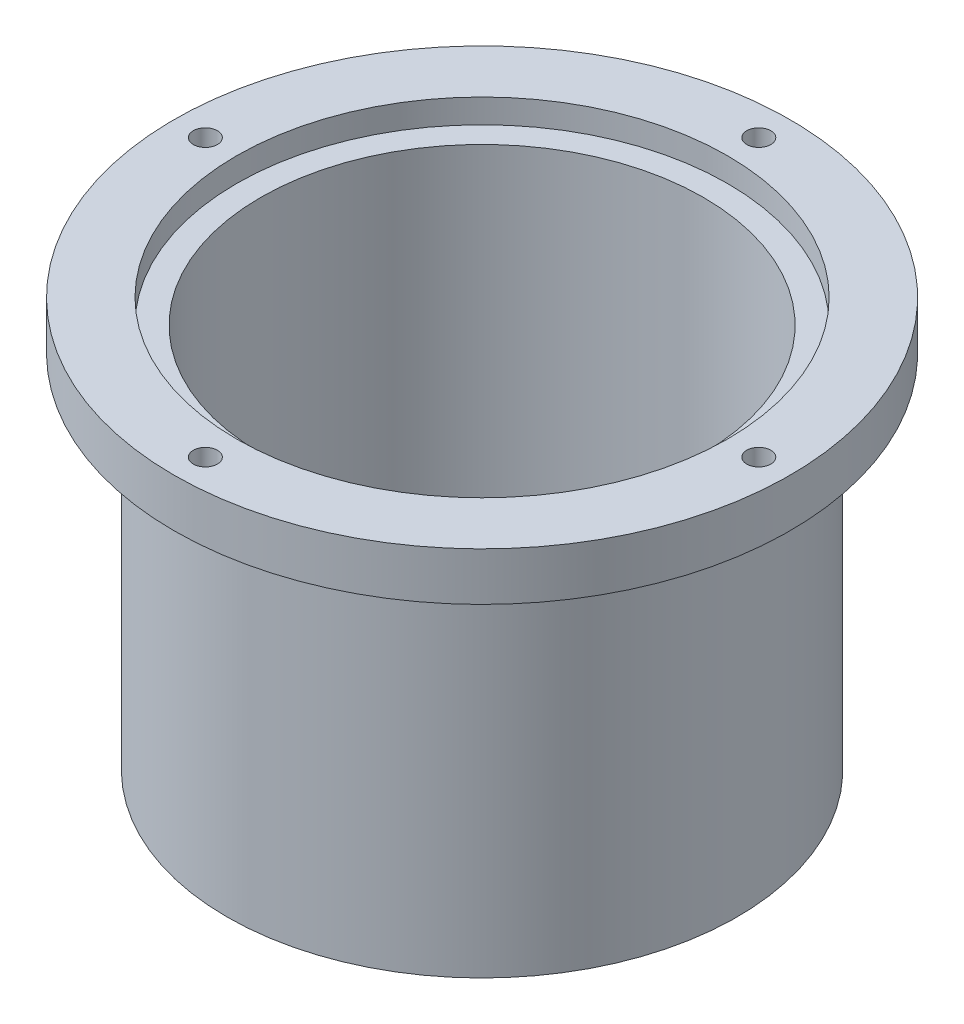
from build123d import *

# Parameters (mm, degrees)
SKETCH1_R           = 53
BOSS_EXTRUDE1_DEPTH = 75
SKETCH2_R           = 64
BOSS_EXTRUDE2_DEPTH = 10
SKETCH3_R           = 51
CUT_EXTRUDE1_DEPTH  = 5
SKETCH5_R           = 46
CUT_EXTRUDE2_DEPTH  = 66
SKETCH6_R           = 2.5
CUT_EXTRUDE3_DEPTH  = 66


with BuildPart() as part:
    # Sketch1 → Boss-Extrude1 (new body)
    with BuildSketch(Plane(origin=(0, 0, 0), x_dir=(1, 0, 0), z_dir=(0, 1, 0))):
        Circle(SKETCH1_R)
    extrude(amount=BOSS_EXTRUDE1_DEPTH)

    # Sketch2 → Boss-Extrude2 (add)
    with BuildSketch(Plane(origin=(0, 75, 0), x_dir=(1, 0, 0), z_dir=(0, 1, 0))):
        Circle(SKETCH2_R)
    extrude(amount=BOSS_EXTRUDE2_DEPTH)

    # Sketch3 → Cut-Extrude1 (cut)
    with BuildSketch(Plane(origin=(0, 85, 0), x_dir=(1, 0, 0), z_dir=(0, 1, 0))):
        Circle(SKETCH3_R)
    extrude(amount=-CUT_EXTRUDE1_DEPTH, mode=Mode.SUBTRACT)

    # Sketch5 → Cut-Extrude2 (cut)
    with BuildSketch(Plane(origin=(0, 80, 0), x_dir=(1, 0, 0), z_dir=(0, 1, 0))):
        Circle(SKETCH5_R)
    extrude(amount=-CUT_EXTRUDE2_DEPTH, mode=Mode.SUBTRACT)

    # Sketch6 → Cut-Extrude3 (cut)
    with BuildSketch(Plane(origin=(0, 85, 0), x_dir=(1, 0, 0), z_dir=(0, 1, 0))):
        with Locations((-57.5, 0)):
            Circle(SKETCH6_R)
        with Locations((0, 57.5)):
            Circle(SKETCH6_R)
        with Locations((57.5, 0)):
            Circle(SKETCH6_R)
        with Locations((0, -57.5)):
            Circle(SKETCH6_R)
    extrude(amount=-CUT_EXTRUDE3_DEPTH, mode=Mode.SUBTRACT)


solid = part.part
